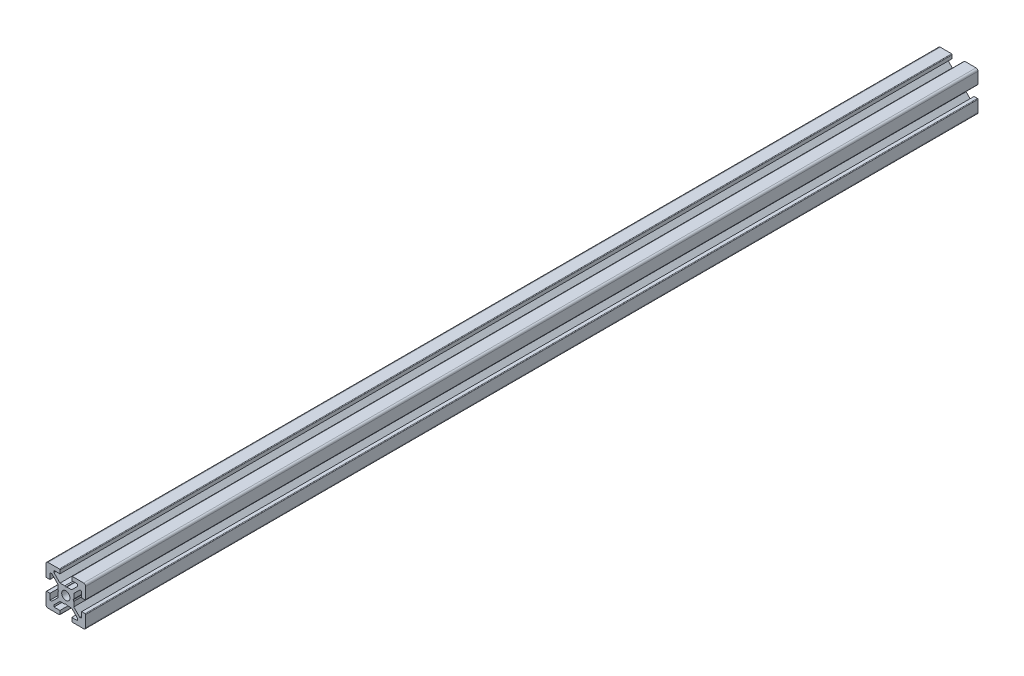
from build123d import *

# Parameters (mm, degrees)
SKETCH1_R           = 2.1
BOSS_EXTRUDE1_DEPTH = 450


with BuildPart() as part:
    # Sketch1 → Boss-Extrude1 (new body)
    with BuildSketch(Plane(origin=(0, 0, 0), x_dir=(-1, 0, 0), z_dir=(0, 0, -1))):
        with BuildLine():
            Line((10, 3.299999891), (10, 9))
            ThreePointArc((10, 9), (9.707106781, 9.707106781), (9, 10))
            Line((9, 10), (3.3, 10))
            ThreePointArc((3.3, 10), (3.087867966, 9.912132034), (3, 9.7))
            Line((3, 9.7), (3, 8))
            Line((3, 8), (6, 8))
            Line((6, 8), (6, 7.0606435))
            Line((6, 7.0606435), (2.93935655, 4))
            Line((2.93935655, 4), (0.519628117, 4))
            Line((0.519628117, 4), (6.437e-06, 3.699996283))
            Line((6.437e-06, 3.699996283), (-0.519615242, 4))
            Line((-0.519615242, 4), (-2.9393308, 4))
            Line((-2.9393308, 4), (-6, 7.060669))
            Line((-6, 7.060669), (-6, 8))
            Line((-6, 8), (-3, 8))
            Line((-3, 8), (-3, 9.700000109))
            ThreePointArc((-3, 9.700000109), (-3.087867934, 9.912132066), (-3.299999891, 10))
            Line((-3.299999891, 10), (-9, 10))
            ThreePointArc((-9, 10), (-9.707106781, 9.707106781), (-10, 9))
            Line((-10, 9), (-10, 3.299999891))
            ThreePointArc((-10, 3.299999891), (-9.912132066, 3.087867934), (-9.700000109, 3))
            Line((-9.700000109, 3), (-8, 3))
            Line((-8, 3), (-8, 6))
            Line((-8, 6), (-7.060651, 6))
            Line((-7.060651, 6), (-4, 2.9393401))
            Line((-4, 2.9393401), (-4, 0.519628117))
            Line((-4, 0.519628117), (-3.699996283, 6.437e-06))
            Line((-3.699996283, 6.437e-06), (-4, -0.519615242))
            Line((-4, -0.519615242), (-4, -2.9393482))
            Line((-4, -2.9393482), (-7.0606435, -6))
            Line((-7.0606435, -6), (-8, -6))
            Line((-8, -6), (-8, -3))
            Line((-8, -3), (-9.700000109, -3))
            ThreePointArc((-9.700000109, -3), (-9.912132066, -3.087867934), (-10, -3.299999891))
            Line((-10, -3.299999891), (-10, -9))
            ThreePointArc((-10, -9), (-9.707106781, -9.707106781), (-9, -10))
            Line((-9, -10), (-3.299999891, -10))
            ThreePointArc((-3.299999891, -10), (-3.087867934, -9.912132066), (-3, -9.700000109))
            Line((-3, -9.700000109), (-3, -8))
            Line((-3, -8), (-6, -8))
            Line((-6, -8), (-6, -7.060677))
            Line((-6, -7.060677), (-2.9393227, -4))
            Line((-2.9393227, -4), (-0.519628117, -4))
            Line((-0.519628117, -4), (-6.437e-06, -3.699996283))
            Line((-6.437e-06, -3.699996283), (0.519615242, -4))
            Line((0.519615242, -4), (2.9393489, -4))
            Line((2.9393489, -4), (6, -7.0606515))
            Line((6, -7.0606515), (6, -8))
            Line((6, -8), (3, -8))
            Line((3, -8), (3, -9.700000109))
            ThreePointArc((3, -9.700000109), (3.087867934, -9.912132066), (3.299999891, -10))
            Line((3.299999891, -10), (9, -10))
            ThreePointArc((9, -10), (9.707106781, -9.707106781), (10, -9))
            Line((10, -9), (10, -3.299999891))
            ThreePointArc((10, -3.299999891), (9.912132066, -3.087867934), (9.700000109, -3))
            Line((9.700000109, -3), (8, -3))
            Line((8, -3), (8, -6))
            Line((8, -6), (7.0606695, -6))
            Line((7.0606695, -6), (4, -2.93933725))
            Line((4, -2.93933725), (4, -0.519628117))
            Line((4, -0.519628117), (3.699996283, -6.437e-06))
            Line((3.699996283, -6.437e-06), (4, 0.519615242))
            Line((4, 0.519615242), (4, 2.93932965))
            Line((4, 2.93932965), (7.060677, 6))
            Line((7.060677, 6), (8, 6))
            Line((8, 6), (8, 3))
            Line((8, 3), (9.700000109, 3))
            ThreePointArc((9.700000109, 3), (9.912132066, 3.087867934), (10, 3.299999891))
        make_face()
        Circle(SKETCH1_R, mode=Mode.SUBTRACT)
    extrude(amount=BOSS_EXTRUDE1_DEPTH)


solid = part.part
